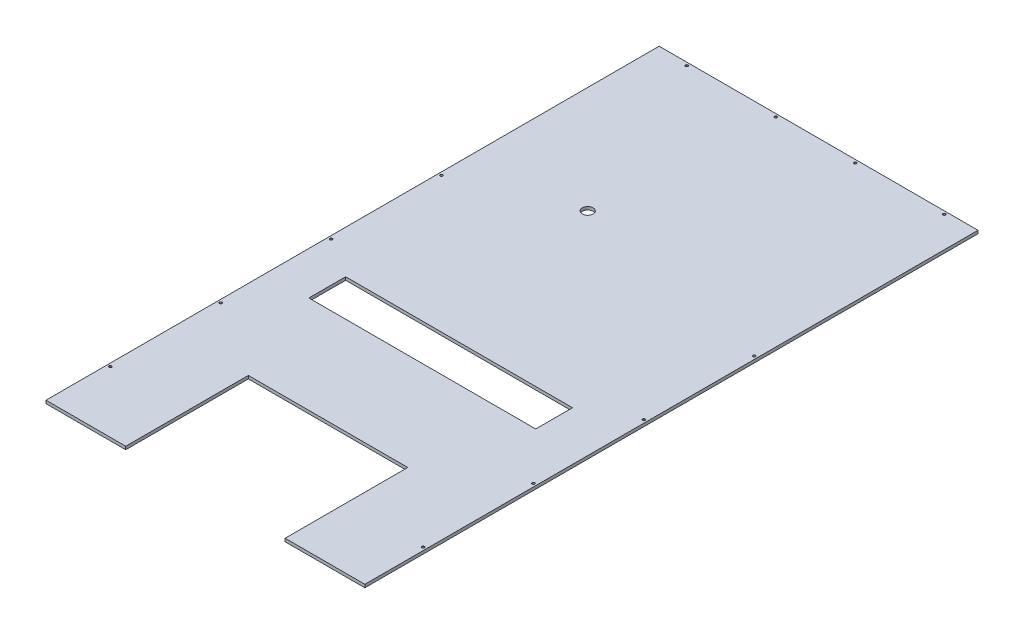
from build123d import *

# Parameters (mm, degrees)
SKETCH1_W                              = 1320.8
SKETCH1_H                              = 12.7
BOSS_EXTRUDE1_DEPTH                    = 2540
SKETCH2_W                              = 660.4
SKETCH2_H                              = 508
CUT_EXTRUDE1_DEPTH                     = 13.7
F_3_8_0_375_DIAMETER_HOLE1_D           = 9.525
F_3_8_0_375_DIAMETER_HOLE1_CSINK_D     = 10.795
F_3_8_0_375_DIAMETER_HOLE1_CSINK_ANGLE = 90
SKETCH5_W                              = 939.8
SKETCH5_H                              = 152.4
CUT_EXTRUDE3_DEPTH                     = 1
CUT_EXTRUDE3_DEPTH_BACK                = 13.7
SKETCH6_R                              = 22.225
CUT_EXTRUDE4_DEPTH                     = 31.75


with BuildPart() as part:
    # Sketch1 → Boss-Extrude1 (new body)
    with BuildSketch(Plane.XY):
        with Locations((660.4, 6.35)):
            Rectangle(SKETCH1_W, SKETCH1_H)
    extrude(amount=BOSS_EXTRUDE1_DEPTH)

    # Sketch2 → Cut-Extrude1 (cut, through all)
    with BuildSketch(Plane(origin=(0, 12.7, 0), x_dir=(1, 0, 0), z_dir=(0, 1, 0))):
        with Locations((660.4, -2286)):
            Rectangle(SKETCH2_W, SKETCH2_H)
    extrude(amount=-CUT_EXTRUDE1_DEPTH, mode=Mode.SUBTRACT)

    # 3/8 (0.375) Diameter Hole1 (through all)
    with Locations(Plane(origin=(0, 12.7, 0), x_dir=(1, 0, 0), z_dir=(0, 1, 0))):
        with Locations((1308.1, -2286), (1308.1, -1828.8), (1308.1, -1371.6), (1308.1, -914.4), (12.7, -2286), (12.7, -1828.8), (12.7, -1371.6), (12.7, -914.4), (495.3, -12.7), (127, -12.7), (1193.8, -12.7), (825.5, -12.7)):
            CounterSinkHole(F_3_8_0_375_DIAMETER_HOLE1_D / 2, F_3_8_0_375_DIAMETER_HOLE1_CSINK_D / 2, counter_sink_angle=F_3_8_0_375_DIAMETER_HOLE1_CSINK_ANGLE)

    # Sketch5 → Cut-Extrude3 (cut, two sides)
    with BuildSketch(Plane(origin=(0, 12.7, 0), x_dir=(1, 0, 0), z_dir=(0, 1, 0))) as cut_extrude3_sk:
        with Locations((647.7, -1552.702)):
            Rectangle(SKETCH5_W, SKETCH5_H)
    extrude(amount=CUT_EXTRUDE3_DEPTH, mode=Mode.SUBTRACT)
    extrude(cut_extrude3_sk.sketch, amount=-CUT_EXTRUDE3_DEPTH_BACK, mode=Mode.SUBTRACT)

    # Sketch6 → Cut-Extrude4 (cut)
    with BuildSketch(Plane(origin=(0, 12.7, 0), x_dir=(1, 0, 0), z_dir=(0, 1, 0))):
        with Locations((442.97784899, -738.973935122)):
            Circle(SKETCH6_R)
    extrude(amount=-CUT_EXTRUDE4_DEPTH, mode=Mode.SUBTRACT)


solid = part.part
